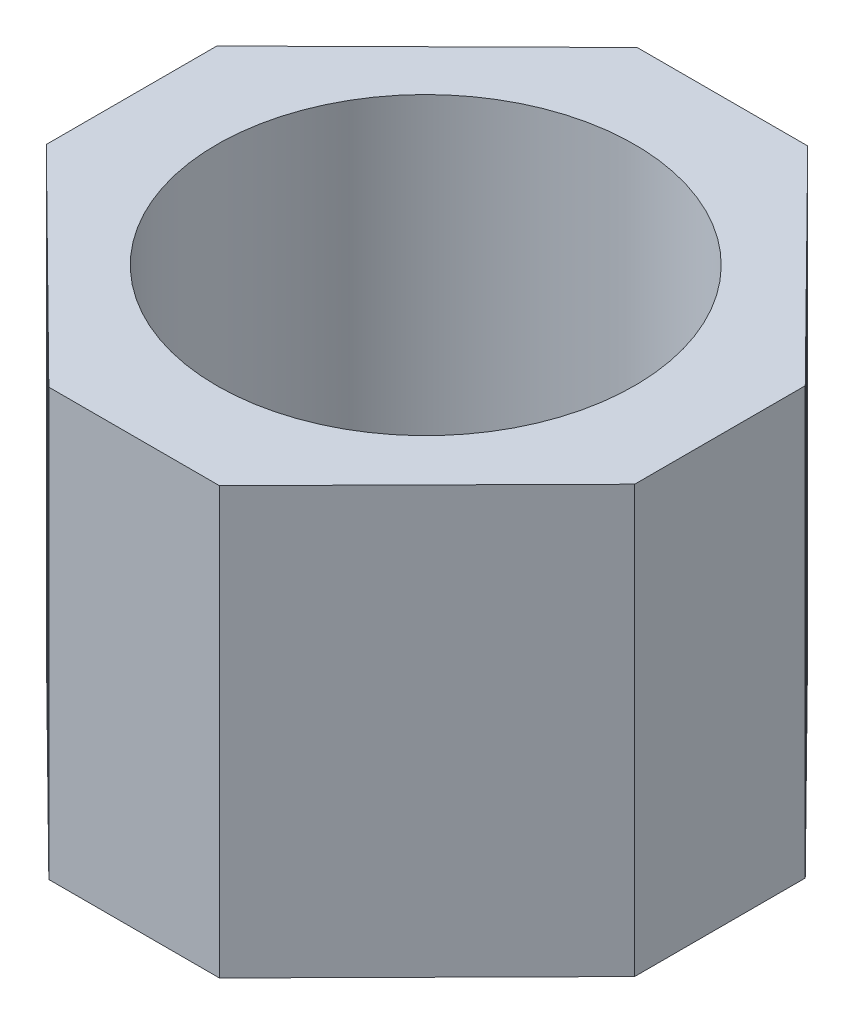
from build123d import *

# Parameters (mm, degrees)
CROQUIS1_R              = 2.45
SALIENTE_EXTRUIR1_DEPTH = 5


with BuildPart() as part:
    # Croquis1 → Saliente-Extruir1 (new body)
    with BuildSketch(Plane(origin=(0, 0, 0), x_dir=(1, 0, 0), z_dir=(0, 1, 0))):
        Polygon((0.029803377, 3.449555781), (-0.970196623, 3.449555781), (-3.45, 1), (-3.45, -1), (-0.970196623, -3.449555781), (0.029803377, -3.449555781), (1.029803377, -3.449555781), (3.45, -1), (3.45, 1), (1.029803377, 3.449555781), align=None)
        Circle(CROQUIS1_R, mode=Mode.SUBTRACT)
    extrude(amount=SALIENTE_EXTRUIR1_DEPTH)


solid = part.part
